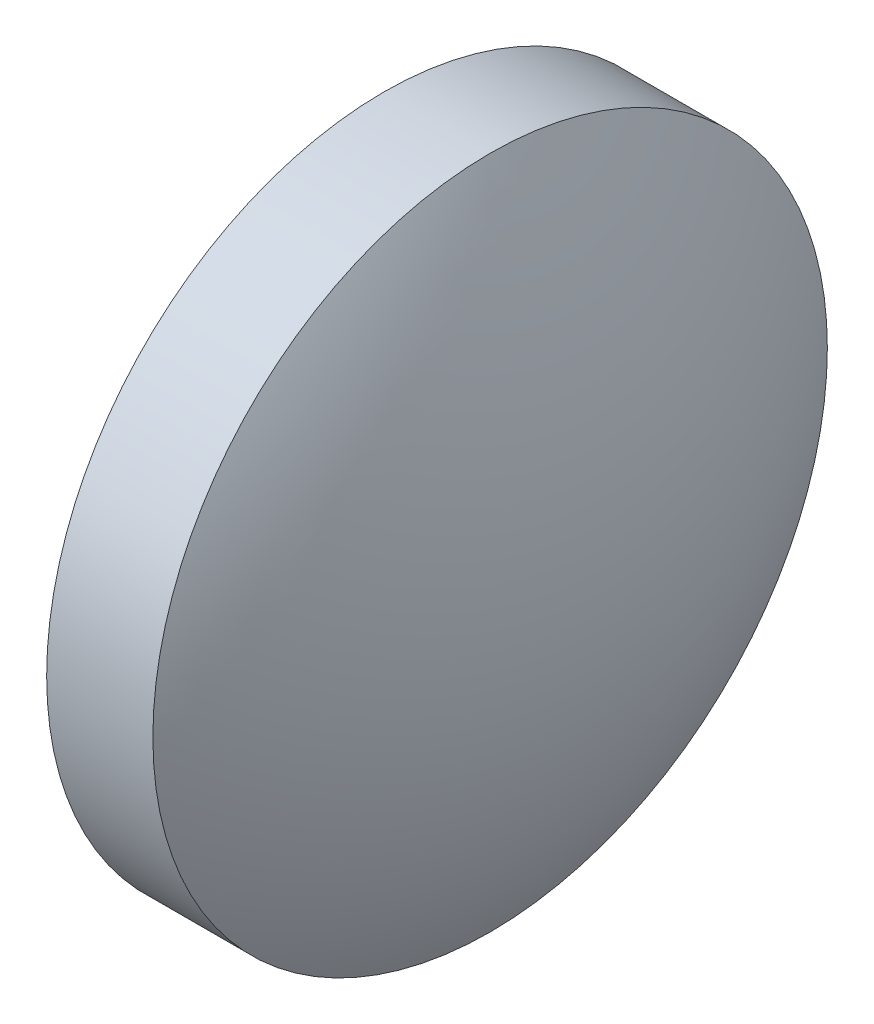
from build123d import *

# Parameters (mm, degrees)
SKETCH_1_ONE_SIDE_W = 2
SKETCH_1_ONE_SIDE_H = 6.349782293


with BuildPart() as part:
    # 草图1 one side → 旋转1 (revolve)
    with BuildSketch(Plane.XY, mode=Mode.PRIVATE) as revolve_1_sk:
        with Locations((43.227614798, 27.482114268)):
            Rectangle(SKETCH_1_ONE_SIDE_W, SKETCH_1_ONE_SIDE_H)
        with BuildLine():
            Line((40.54800667, 24.307223121), (42.227614798, 24.307223121))
            Line((42.227614798, 24.307223121), (42.227614798, 30.657005414))
            ThreePointArc((42.227614798, 30.657005414), (40.975007368, 27.591306655), (40.54800667, 24.307223121))
        make_face()
        with BuildLine():
            Line((44.227614798, 24.307223121), (45.907222925, 24.307223121))
            ThreePointArc((45.907222925, 24.307223121), (45.480222227, 27.591306655), (44.227614798, 30.657005414))
            Line((44.227614798, 30.657005414), (44.227614798, 24.307223121))
        make_face()
    revolve(revolve_1_sk.sketch.rotate(Axis((39.651341201, 24.307223121, 0), (1, 0, 0)), 90), axis=Axis((39.651341201, 24.307223121, 0), (1, 0, 0)))  # turned: the seam where the file's is


solid = part.part
